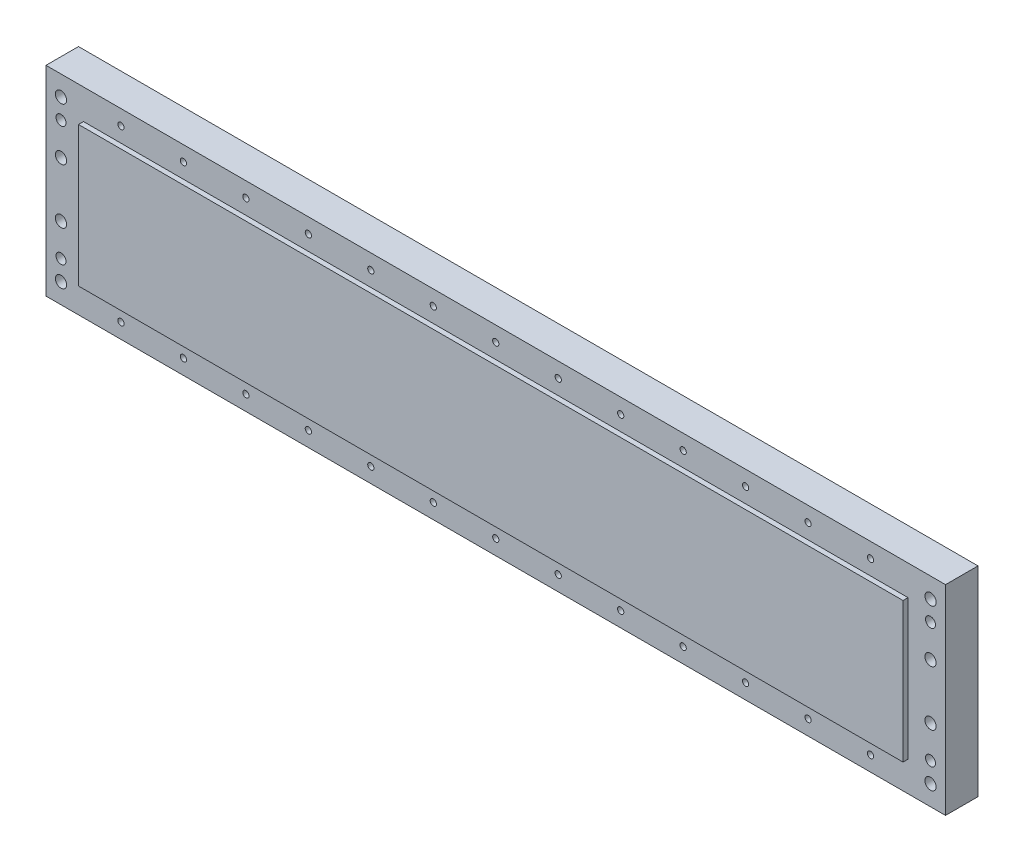
from build123d import *

# Parameters (mm, degrees)
CROQUIS1_W                                           = 360
CROQUIS1_H                                           = 80
SALIENTE_EXTRUIR1_DEPTH                              = 15
CROQUIS2_W                                           = 360
CROQUIS2_H                                           = 80
CROQUIS2_W_2                                         = 330
CROQUIS2_H_2                                         = 56
CORTAR_EXTRUIR1_DEPTH                                = 2
REFRENTADO_PARA_TORNILLO_CON_CABEZA_HUEC_D           = 4.5
REFRENTADO_PARA_TORNILLO_CON_CABEZA_HUEC_CBORE_D     = 8
REFRENTADO_PARA_TORNILLO_CON_CABEZA_HUEC_CBORE_DEPTH = 4.4
TALADROS_DE_ESPIGA_DE_4_0MM1_D                       = 4
TALADRO_ROSCADO_M3X0_351_D                           = 2.65
TALADRO_ROSCADO_M3X0_351_DEPTH                       = 7.75
TALADRO_ROSCADO_M3X0_351_TIP                         = 0.79614032
MATRIZL1_COUNT                                       = 13
MATRIZL1_PITCH                                       = 25
MATRIZL1_COUNT_DIR2                                  = 2
MATRIZL1_PITCH_DIR2                                  = 68


with BuildPart() as part:
    # Croquis1 → Saliente-Extruir1 (new body)
    with BuildSketch(Plane.XY):
        with Locations((180, 40)):
            Rectangle(CROQUIS1_W, CROQUIS1_H)
    extrude(amount=SALIENTE_EXTRUIR1_DEPTH)

    # Croquis2 → Cortar-Extruir1 (cut)
    with BuildSketch(Plane.XY.offset(15)):
        with Locations((180, 40)):
            Rectangle(CROQUIS2_W, CROQUIS2_H)
        with Locations((180, 40)):
            Rectangle(CROQUIS2_W_2, CROQUIS2_H_2, mode=Mode.SUBTRACT)
    extrude(amount=-CORTAR_EXTRUIR1_DEPTH, mode=Mode.SUBTRACT)

    # Croquis4 → Taladro roscado M31 (revolve, cut)
    with BuildSketch(Plane(origin=(30, 6, 13), x_dir=(0, -1, 0), z_dir=(1, 0, 0))):
        Polygon((0, 0), (0, 7.751075774), (1.25, 7), (1.25, 0), align=None)
    taladro_roscado_m31 = revolve(axis=Axis((30, 6, 19.35), (0, 0, -1)), mode=Mode.SUBTRACT)

    # Refrentado para tornillo con cabeza hueca de M41 (through all)
    with Locations(Plane(origin=(0, 0, 0), x_dir=(-1, 0, 0), z_dir=(0, 0, -1))):
        with Locations((-6, 72), (-6, 8), (-354, 72), (-354, 8), (-354, 51), (-354, 29), (-6, 51), (-6, 29)):
            CounterBoreHole(REFRENTADO_PARA_TORNILLO_CON_CABEZA_HUEC_D / 2, REFRENTADO_PARA_TORNILLO_CON_CABEZA_HUEC_CBORE_D / 2, REFRENTADO_PARA_TORNILLO_CON_CABEZA_HUEC_CBORE_DEPTH)

    # Taladros de espiga de Ø4.0mm1 (through all)
    with Locations(Plane(origin=(0, 0, 0), x_dir=(-1, 0, 0), z_dir=(0, 0, -1))):
        with Locations((-6, 64), (-6, 16), (-354, 64), (-354, 16)):
            Hole(TALADROS_DE_ESPIGA_DE_4_0MM1_D / 2)

    # Taladro roscado M3x0.351
    with Locations(Plane(origin=(0, 0, 0), x_dir=(-1, 0, 0), z_dir=(0, 0, -1))):
        with Locations((-21, 73.5), (-51, 73.5), (-51, 6.5), (-21, 6.5)):
            Hole(TALADRO_ROSCADO_M3X0_351_D / 2, depth=TALADRO_ROSCADO_M3X0_351_DEPTH)
            with Locations((0, 0, -(TALADRO_ROSCADO_M3X0_351_DEPTH + TALADRO_ROSCADO_M3X0_351_TIP / 2))):  # 118° drill point
                Cone(0, TALADRO_ROSCADO_M3X0_351_D / 2, TALADRO_ROSCADO_M3X0_351_TIP, mode=Mode.SUBTRACT)

    # MatrizL1: Taladro roscado M31 13 × 2
    with Locations(*[(i * MATRIZL1_PITCH, j * MATRIZL1_PITCH_DIR2, 0) for i in range(MATRIZL1_COUNT) for j in range(MATRIZL1_COUNT_DIR2) if (i, j) != (0, 0)]):
        add(taladro_roscado_m31, mode=Mode.SUBTRACT)


solid = part.part
